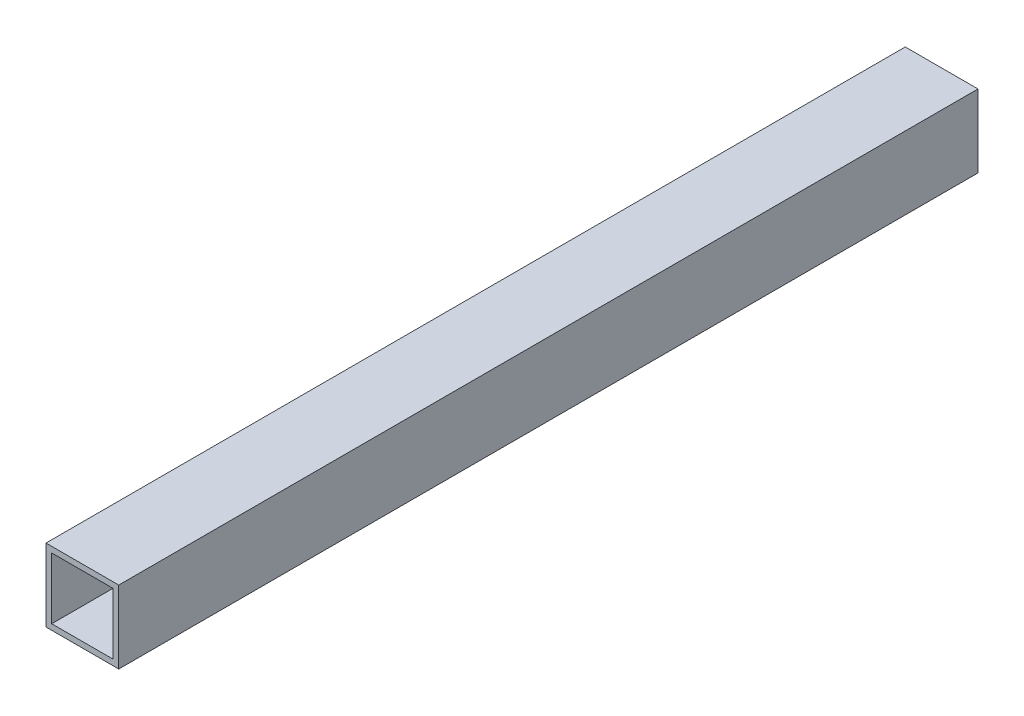
from build123d import *

# Parameters (mm, degrees)
SKETCH1_W           = 25.4
SKETCH1_H           = 25.4
SKETCH1_W_2         = 21.4
SKETCH1_H_2         = 21.4
BOSS_EXTRUDE1_DEPTH = 300


with BuildPart() as part:
    # Sketch1 → Boss-Extrude1 (new body)
    with BuildSketch(Plane.XY):
        Rectangle(SKETCH1_W, SKETCH1_H)
        Rectangle(SKETCH1_W_2, SKETCH1_H_2, mode=Mode.SUBTRACT)
    extrude(amount=BOSS_EXTRUDE1_DEPTH)


solid = part.part
